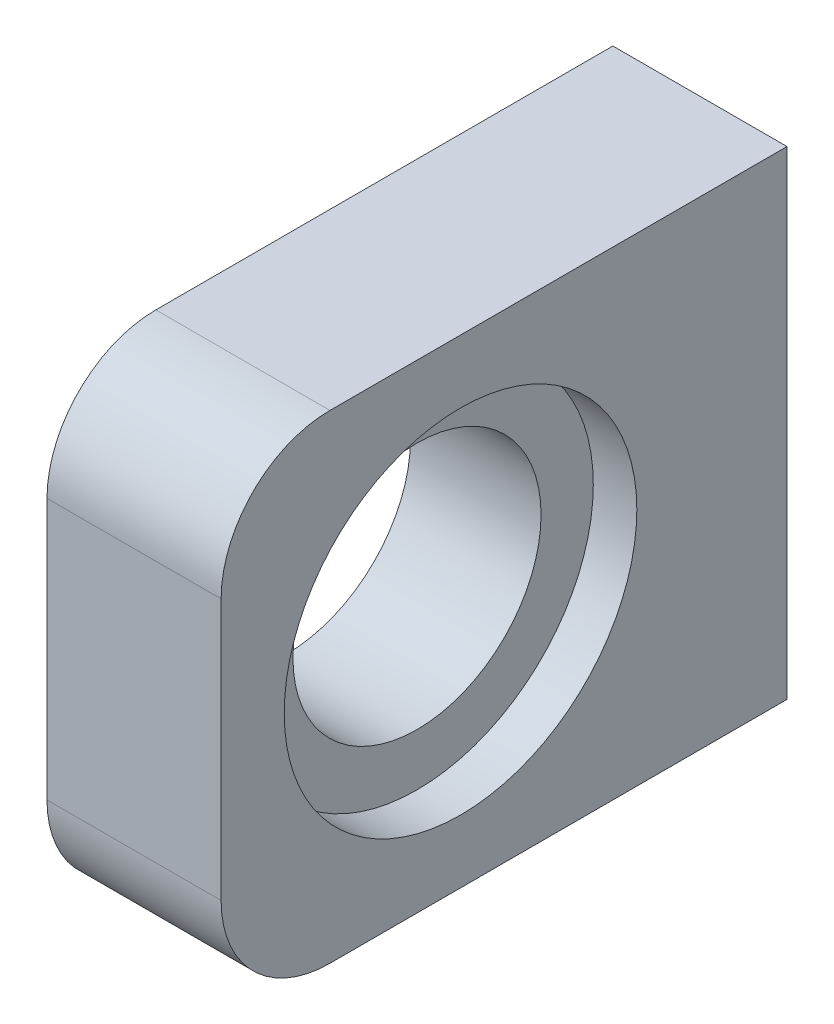
from build123d import *

# Parameters (mm, degrees)
SKETCH1_W                      = 26
SKETCH1_H                      = 22
BOSS_EXTRUDE1_DEPTH            = 8
SKETCH2_R                      = 8.1
CUT_EXTRUDE1_DEPTH             = 2
F_3_3_3_3_DIAMETER_HOLE1_D     = 3.3
F_3_3_3_3_DIAMETER_HOLE1_DEPTH = 6
F_3_3_3_3_DIAMETER_HOLE1_TIP   = 0.991420021
M10_CLEARANCE_HOLE1_D          = 11.4
FILLET1_R                      = 5


with BuildPart() as part:
    # Sketch1 → Boss-Extrude1 (new body)
    with BuildSketch(Plane(origin=(8, 0, 0), x_dir=(0, 0, -1), z_dir=(1, 0, 0))):
        with Locations((-9, 11)):
            Rectangle(SKETCH1_W, SKETCH1_H)
    extrude(amount=-BOSS_EXTRUDE1_DEPTH)

    # Sketch2 → Cut-Extrude1 (cut)
    with BuildSketch(Plane(origin=(8, 0, 0), x_dir=(0, 0, -1), z_dir=(1, 0, 0))):
        with Locations((-11, 11)):
            Circle(SKETCH2_R)
    extrude(amount=-CUT_EXTRUDE1_DEPTH, mode=Mode.SUBTRACT)

    # Ø3.3 (3.3) Diameter Hole1
    with Locations(Plane(origin=(0, 0, -4), x_dir=(-1, 0, 0), z_dir=(0, 0, -1))):
        with Locations((-4, 16), (-4, 6)):
            Hole(F_3_3_3_3_DIAMETER_HOLE1_D / 2, depth=F_3_3_3_3_DIAMETER_HOLE1_DEPTH)
            with Locations((0, 0, -(F_3_3_3_3_DIAMETER_HOLE1_DEPTH + F_3_3_3_3_DIAMETER_HOLE1_TIP / 2))):  # 118° drill point
                Cone(0, F_3_3_3_3_DIAMETER_HOLE1_D / 2, F_3_3_3_3_DIAMETER_HOLE1_TIP, mode=Mode.SUBTRACT)

    # M10 Clearance Hole1 (through all)
    with Locations(Plane(origin=(6, 0, 0), x_dir=(0, 0, -1), z_dir=(1, 0, 0))):
        with Locations((-11, 11)):
            Hole(M10_CLEARANCE_HOLE1_D / 2)

    # Fillet1
    fillet1_edges = [part.edges().sort_by_distance(p)[0] for p in [
        (4, 0, 22),
        (4, 22, 22),
    ]]
    fillet(fillet1_edges, radius=FILLET1_R)


solid = part.part
